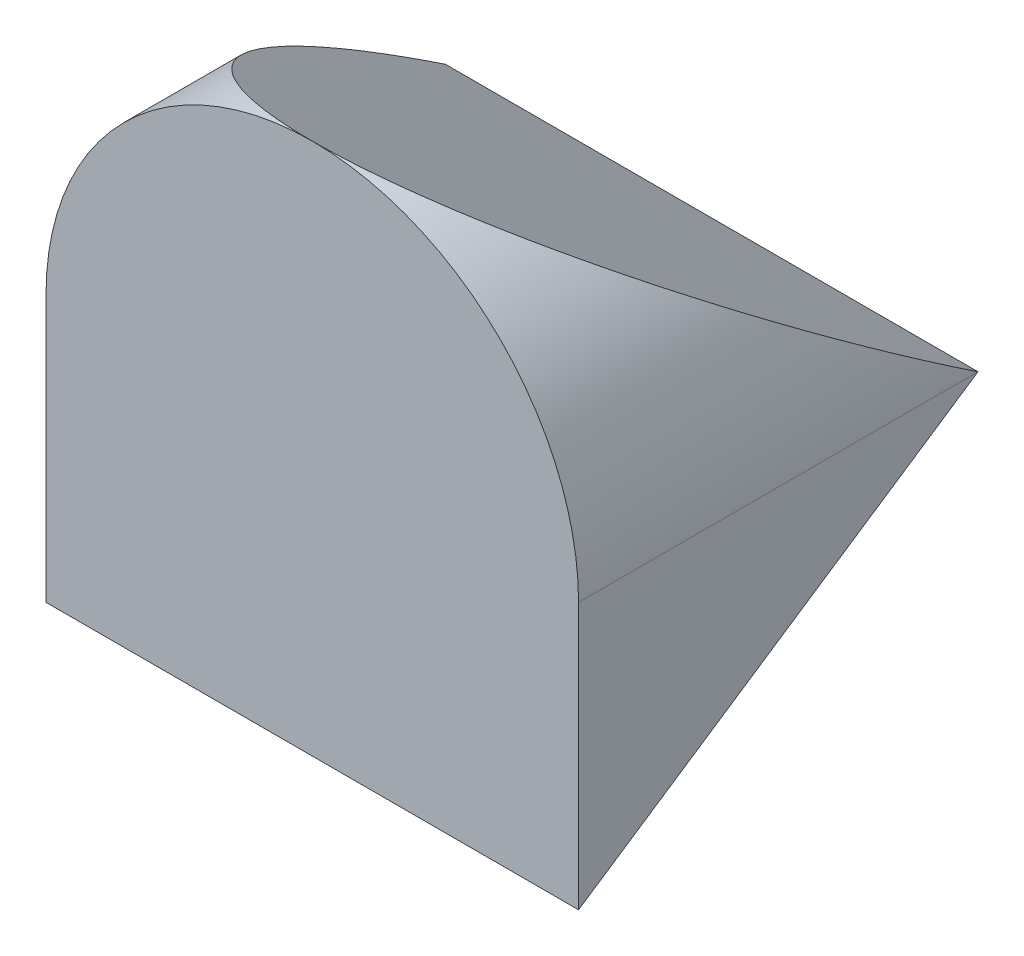
from build123d import *

# Parameters (mm, degrees)
SKETCH1_R           = 10
BOSS_EXTRUDE1_DEPTH = 15
CUT_EXTRUDE1_DEPTH  = 16
CUT_EXTRUDE2_DEPTH  = 10
CUT_EXTRUDE3_DEPTH  = 10
SKETCH7_W           = 15
SKETCH7_H           = 10
BOSS_EXTRUDE2_DEPTH = 10
CUT_EXTRUDE4_DEPTH  = 20


with BuildPart() as part:
    # Sketch1 → Boss-Extrude1 (new body)
    with BuildSketch(Plane.XY):
        Circle(SKETCH1_R)
    extrude(amount=BOSS_EXTRUDE1_DEPTH)

    # Sketch2 → Cut-Extrude1 (cut, through all)
    with BuildSketch(Plane.XY.offset(15)):
        with BuildLine():
            Line((0, 0), (10, 0))
            ThreePointArc((10, 0), (7.071067812, -7.071067812), (0, -10))
            Line((0, -10), (0, 0))
        make_face()
    extrude(amount=-CUT_EXTRUDE1_DEPTH, mode=Mode.SUBTRACT)

    # Sketch5 → Cut-Extrude2 (cut)
    with BuildSketch(Plane(origin=(10, 0, 0), x_dir=(0, 0, -1), z_dir=(1, 0, 0))):
        Polygon((0, 0), (0, 10), (-15, 10), align=None)
    extrude(amount=-CUT_EXTRUDE2_DEPTH, mode=Mode.SUBTRACT)

    # Sketch6 → Cut-Extrude3 (cut)
    with BuildSketch(Plane(origin=(0, 0, 0), x_dir=(0, 0, -1), z_dir=(1, 0, 0))):
        Polygon((-15, 10), (0, 0), (0, 10), align=None)
    extrude(amount=-CUT_EXTRUDE3_DEPTH, mode=Mode.SUBTRACT)

    # Sketch7 → Boss-Extrude2 (add, symmetric)
    with BuildSketch(Plane(origin=(0, 0, 0), x_dir=(0, 0, -1), z_dir=(1, 0, 0))):
        with Locations((-7.5, -5)):
            Rectangle(SKETCH7_W, SKETCH7_H)
    extrude(amount=BOSS_EXTRUDE2_DEPTH, both=True)

    # Sketch8 → Cut-Extrude4 (cut)
    with BuildSketch(Plane(origin=(10, 0, 0), x_dir=(0, 0, -1), z_dir=(1, 0, 0))):
        Polygon((0, 0), (-15, -10), (0, -10), align=None)
    extrude(amount=-CUT_EXTRUDE4_DEPTH, mode=Mode.SUBTRACT)


solid = part.part
